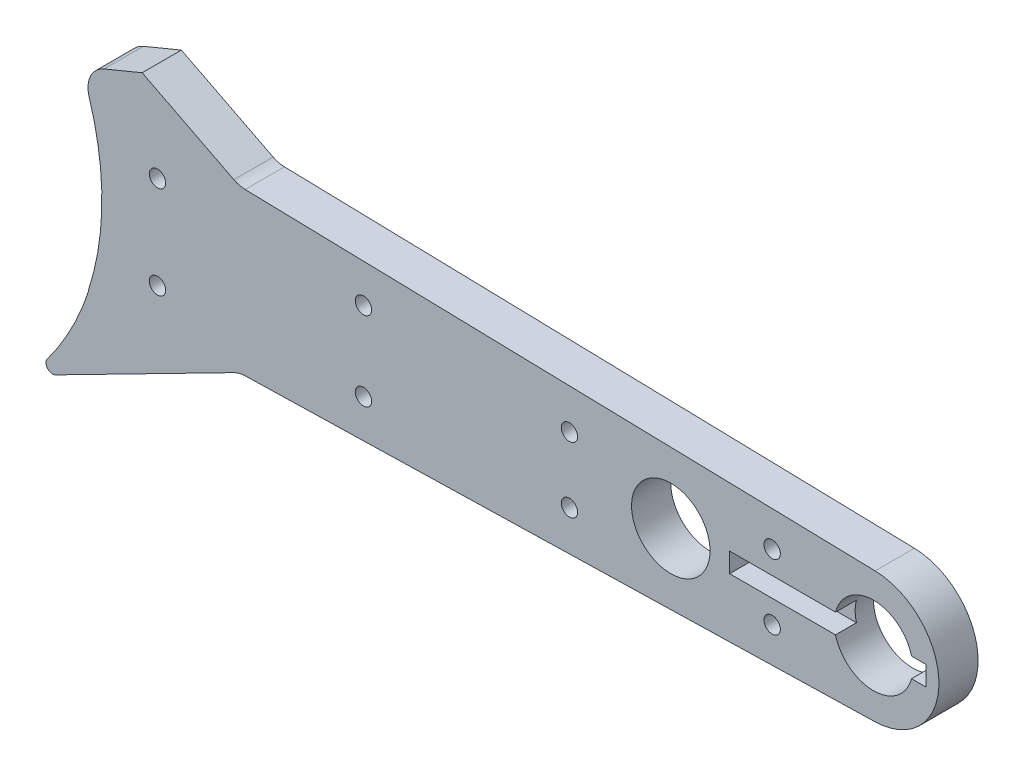
from build123d import *

# Parameters (mm, degrees)
SKETCH1_R                = 13.5
SKETCH1_R_2              = 3
BOSS_EXTRUDE1_DEPTH      = 3
M2_CLEARANCE_HOLE1_D     = 2.4
M2_CLEARANCE_HOLE1_DEPTH = 11.5
CIRPATTERN1_COUNT        = 12
TROU_TARAUD_M1_61_D      = 1.25
ESQUISSE1_R              = 21
ENL_V_MAT_EXTRU_1_DEPTH  = 4
ESQUISSE2_R              = 0.625
ENL_V_MAT_EXTRU_2_DEPTH  = 4
ESQUISSE4_W              = 15
ESQUISSE4_H              = 1.5
ENL_V_MAT_EXTRU_3_DEPTH  = 1.6
ESQUISSE5_R              = 0.625
ENL_V_MAT_EXTRU_4_DEPTH  = 10
BOSS_EXTRU_3_DEPTH       = 3
CONG_2_R                 = 2
CONG_3_R                 = 2
CONG_4_R                 = 0.5


with BuildPart() as part:
    # Sketch1 → Boss-Extrude1 (new body)
    with BuildSketch(Plane.XY):
        with BuildLine():
            Line((18.384776311, 6.5), (80.121567237, 4.998521922))
            ThreePointArc((80.121567237, 4.998521922), (85, 0), (80.121567237, -4.998521922))
            Line((80.121567237, -4.998521922), (18.384776311, -6.5))
            ThreePointArc((18.384776311, -6.5), (-19.5, 0), (18.384776311, 6.5))
        make_face()
        Circle(SKETCH1_R, mode=Mode.SUBTRACT)
        with Locations((64.5, 0)):
            Circle(SKETCH1_R_2, mode=Mode.SUBTRACT)
        with Locations((80, 0)):
            Circle(SKETCH1_R_2, mode=Mode.SUBTRACT)
    extrude(amount=BOSS_EXTRUDE1_DEPTH)

    # M2 Clearance Hole1
    with Locations(Plane.XY.offset(3)):
        with Locations((0, 16.5)):
            m2_clearance_hole1 = Hole(M2_CLEARANCE_HOLE1_D / 2, depth=M2_CLEARANCE_HOLE1_DEPTH)

    # CirPattern1: M2 Clearance Hole1 ×12 about axis
    cirpattern1_axis = Axis((0, 0, 0), (0, 0, 1))
    for i in range(1, CIRPATTERN1_COUNT):
        add(m2_clearance_hole1.rotate(cirpattern1_axis, i * 360 / CIRPATTERN1_COUNT), mode=Mode.SUBTRACT)

    # Trou taraudé M1.61 (through all)
    with Locations(Plane.XY.offset(3)):
        with Locations((56.75, 2.5), (72.25, 2.5), (72.25, -2.5), (56.75, -2.5)):
            Hole(TROU_TARAUD_M1_61_D / 2)

    # Esquisse1 → Enlèv. mat.-Extru.1 (cut, through all)
    with BuildSketch(Plane.XY.offset(3)):
        Circle(ESQUISSE1_R)
    extrude(amount=-ENL_V_MAT_EXTRU_1_DEPTH, mode=Mode.SUBTRACT)

    # Esquisse2 → Enlèv. mat.-Extru.2 (cut, through all)
    with BuildSketch(Plane.XY.offset(3)):
        with Locations((25.251835753, 3.548914074)):
            Circle(ESQUISSE2_R)
        with Locations((25.251835753, -3.548914074)):
            Circle(ESQUISSE2_R)
    extrude(amount=-ENL_V_MAT_EXTRU_2_DEPTH, mode=Mode.SUBTRACT)

    # Esquisse4 → Enlèv. mat.-Extru.3 (cut)
    with BuildSketch(Plane.XY.offset(3)):
        with Locations((76.5, 0)):
            Rectangle(ESQUISSE4_W, ESQUISSE4_H)
    extrude(amount=-ENL_V_MAT_EXTRU_3_DEPTH, mode=Mode.SUBTRACT)

    # Esquisse5 → Enlèv. mat.-Extru.4 (cut)
    with BuildSketch(Plane.XY.offset(3)):
        with Locations((41.000917876, 3.024457037)):
            Circle(ESQUISSE5_R)
        with Locations((41.000917876, -3.024457037)):
            Circle(ESQUISSE5_R)
    extrude(amount=-ENL_V_MAT_EXTRU_4_DEPTH, mode=Mode.SUBTRACT)

    # Esquisse6 → Boss.-Extru.3 (add)
    with BuildSketch(Plane.XY.offset(3)):
        with BuildLine():
            Line((19.981323023, 6.461170967), (31.5, 6.181029406))
            Line((31.5, 6.181029406), (24.077934309, 9.962760764))
            Line((24.077934309, 9.962760764), (19.405232048, 8.027264114))
            ThreePointArc((19.405232048, 8.027264114), (19.708839185, 7.249941929), (19.981323023, 6.461170967))
        make_face()
        with BuildLine():
            Line((15.240466078, -14.489207955), (31.5, -6.181029406))
            Line((31.5, -6.181029406), (20.01179148, -6.460429955))
            ThreePointArc((20.01179148, -6.460429955), (18.077492491, -10.743054438), (15.240466078, -14.489207955))
        make_face()
    extrude(amount=-BOSS_EXTRU_3_DEPTH)

    # Congé2
    cong_2_edges = [part.edges().sort_by_distance(p)[0] for p in [
        (19.405232048, 8.027264114, 1.5),
    ]]
    fillet(cong_2_edges, radius=CONG_2_R)

    # Congé3
    cong_3_edges = [part.edges().sort_by_distance(p)[0] for p in [
        (31.5, 6.181029406, 1.5),
        (31.5, -6.181029406, 1.5),
    ]]
    fillet(cong_3_edges, radius=CONG_3_R)

    # Congé4
    cong_4_edges = [part.edges().sort_by_distance(p)[0] for p in [
        (15.240466078, -14.489207955, 1.5),
    ]]
    fillet(cong_4_edges, radius=CONG_4_R)


solid = part.part
